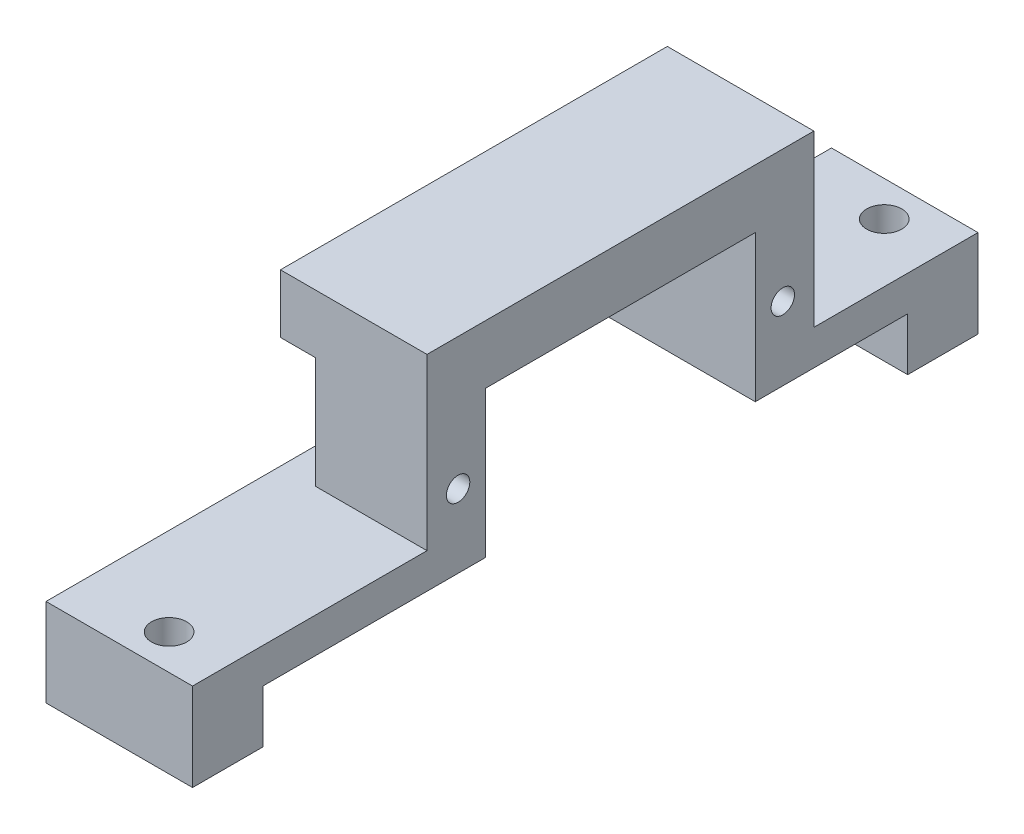
from build123d import *

# Parameters (mm, degrees)
BOSS_EXTRUDE1_DEPTH = 12.5
SKETCH3_R           = 1.5
CUT_EXTRUDE1_DEPTH  = 12.5
SKETCH4_W           = 3
SKETCH4_H           = 9.5
CUT_EXTRUDE2_DEPTH  = 5
SKETCH5_R           = 1
CUT_EXTRUDE3_DEPTH  = 3


with BuildPart() as part:
    # Sketch2 → Boss-Extrude1 (new body)
    with BuildSketch(Plane(origin=(0, 0, 0), x_dir=(0, 0, -1), z_dir=(1, 0, 0))):
        Polygon((6, 0), (25, 0), (25, 12.5), (48, 12.5), (48, 0), (61, 0), (61, -4.5), (67, -4.5), (67, 0), (67, 3), (53, 3), (53, 17.5), (20, 17.5), (20, 3), (0, 3), (0, 0), (0, -4.5), (6, -4.5), align=None)
    extrude(amount=BOSS_EXTRUDE1_DEPTH)

    # Sketch3 → Cut-Extrude1 (cut)
    with BuildSketch(Plane(origin=(0, 3, 0), x_dir=(1, 0, 0), z_dir=(0, 1, 0))):
        with Locations((7.5, 3)):
            Circle(SKETCH3_R)
        with Locations((7.5, 64)):
            Circle(SKETCH3_R)
    extrude(amount=-CUT_EXTRUDE1_DEPTH, mode=Mode.SUBTRACT)

    # Sketch4 → Cut-Extrude2 (cut)
    with BuildSketch(Plane.XY.offset(-20)):
        with Locations((1.5, 7.75)):
            Rectangle(SKETCH4_W, SKETCH4_H)
    extrude(amount=-CUT_EXTRUDE2_DEPTH, mode=Mode.SUBTRACT)

    # Sketch5 → Cut-Extrude3 (cut)
    with BuildSketch(Plane(origin=(12.5, 0, 0), x_dir=(0, 0, -1), z_dir=(1, 0, 0))):
        with Locations((22.65, 6.25)):
            Circle(SKETCH5_R)
        with Locations((50.35, 6.25)):
            Circle(SKETCH5_R)
    extrude(amount=-CUT_EXTRUDE3_DEPTH, mode=Mode.SUBTRACT)


solid = part.part
